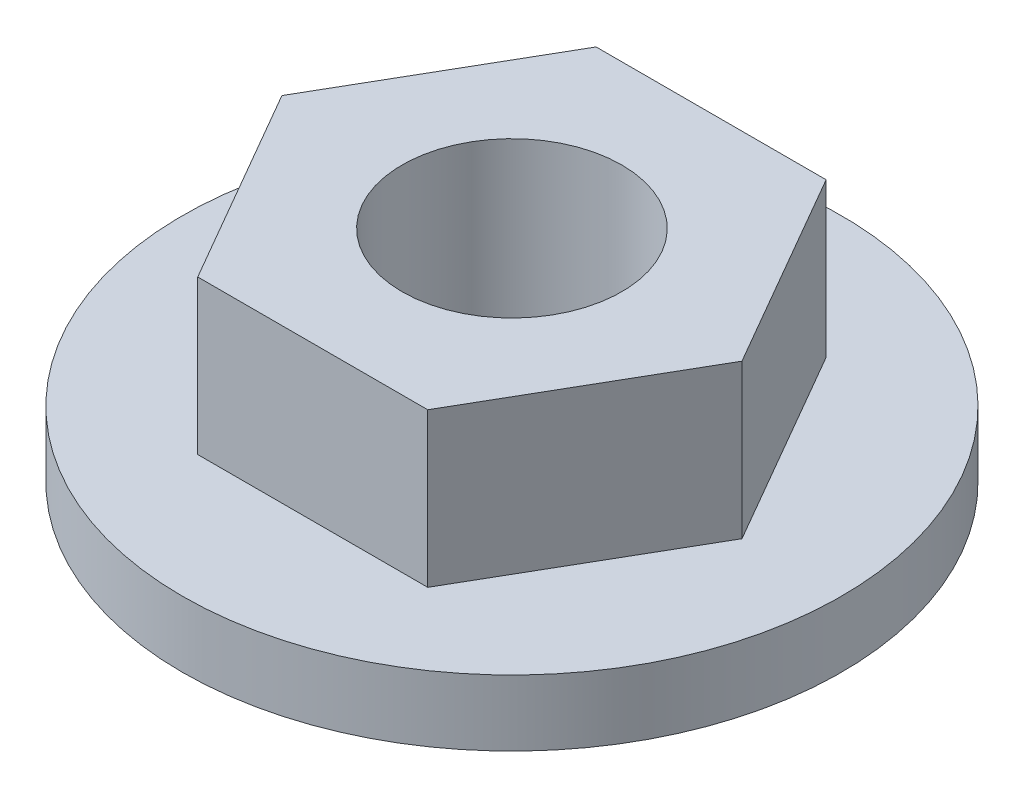
from build123d import *

# Parameters (mm, degrees)
SKETCH3_R           = 9.525
SKETCH3_R_2         = 3.175
BOSS_EXTRUDE1_DEPTH = 1.905
SKETCH4_R           = 3.175
BOSS_EXTRUDE2_DEPTH = 4.445


with BuildPart() as part:
    # Sketch3 → Boss-Extrude1 (new body)
    with BuildSketch(Plane(origin=(0, 0, 0), x_dir=(1, 0, 0), z_dir=(0, 1, 0))):
        Circle(SKETCH3_R)
        Circle(SKETCH3_R_2, mode=Mode.SUBTRACT)
    extrude(amount=BOSS_EXTRUDE1_DEPTH)

    # Sketch4 → Boss-Extrude2 (add)
    with BuildSketch(Plane(origin=(0, 1.905, 0), x_dir=(1, 0, 0), z_dir=(0, 1, 0))):
        Polygon((6.647647659, 0), (3.323823829, 5.757031748), (-3.323823829, 5.757031748), (-6.647647659, 0), (-3.323823829, -5.757031748), (3.323823829, -5.757031748), align=None)
        Circle(SKETCH4_R, mode=Mode.SUBTRACT)
    extrude(amount=BOSS_EXTRUDE2_DEPTH)


solid = part.part
